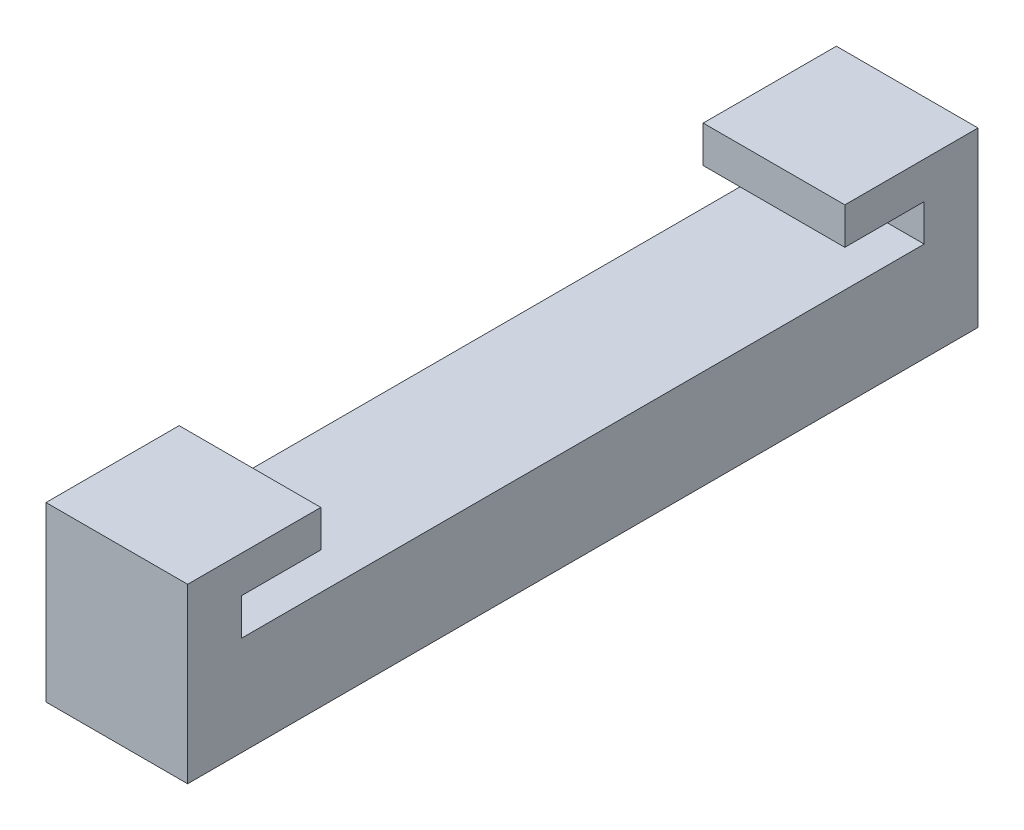
from build123d import *

# Parameters (mm, degrees)
BOSS_EXTRUDE1_DEPTH = 12.7
BOSS_EXTRUDE3_DEPTH = 12.7
CUT_EXTRUDE1_REACH  = 14.7
CUT_EXTRUDE2_REACH  = 14.7
SKETCH6_W           = 7.112
SKETCH6_H           = 3.302
BOSS_EXTRUDE4_DEPTH = 3.175
SKETCH7_W           = 7.112
SKETCH7_H           = 3.302
BOSS_EXTRUDE5_DEPTH = 3.175
CUT_EXTRUDE3_REACH  = 14.7
SKETCH8_W           = 7.112
SKETCH8_H           = 3.302
CUT_EXTRUDE4_REACH  = 14.7
SKETCH9_W           = 7.112
SKETCH9_H           = 3.302


with BuildPart() as part:
    # Sketch1 → Boss-Extrude1 (new body)
    with BuildSketch(Plane(origin=(0, 0, 0), x_dir=(0, 0, -1), z_dir=(1, 0, 0))):
        Polygon((0, 0), (80.01, 0), (80.01, 19.05), (71.12, 19.05), (71.12, 8.89), (8.89, 8.89), (8.89, 19.05), (0, 19.05), align=None)
    extrude(amount=BOSS_EXTRUDE1_DEPTH)

    # Sketch2 → Boss-Extrude3 (add)
    with BuildSketch(Plane.ZY):
        Polygon((-63.5, 12.192), (-70.612, 12.192), (-70.612, 8.89), (-74.93, 8.89), (-74.93, 15.494), (-63.5, 15.494), align=None)
        Polygon((-16.51, 12.192), (-9.398, 12.192), (-9.398, 8.89), (-5.08, 8.89), (-5.08, 15.494), (-16.51, 15.494), align=None)
    extrude(amount=-BOSS_EXTRUDE3_DEPTH)

    # Sketch4 → Cut-Extrude1 (cut, up to next)
    with BuildSketch(Plane.ZY, mode=Mode.PRIVATE) as cut_extrude1_sk1:
        Polygon((-71.12, 15.494), (-75.438, 15.494), (-75.438, 0), (-80.01, 0), (-80.01, 19.05), (-71.12, 19.05), align=None)
    cut_extrude1_tool1 = extrude(cut_extrude1_sk1.sketch, amount=-CUT_EXTRUDE1_REACH, mode=Mode.PRIVATE) & part.part
    add(cut_extrude1_tool1.solids().sort_by_distance((0, 10.686074, -77.05781))[0], mode=Mode.SUBTRACT)

    # Sketch5 → Cut-Extrude2 (cut, up to next)
    with BuildSketch(Plane.ZY, mode=Mode.PRIVATE) as cut_extrude2_sk1:
        Polygon((-8.89, 15.494), (-4.572, 15.494), (-4.572, 0), (0, 0), (0, 19.05), (-8.89, 19.05), align=None)
    cut_extrude2_tool1 = extrude(cut_extrude2_sk1.sketch, amount=-CUT_EXTRUDE2_REACH, mode=Mode.PRIVATE) & part.part
    add(cut_extrude2_tool1.solids().sort_by_distance((0, 10.686074, -2.95219))[0], mode=Mode.SUBTRACT)

    # Sketch6 → Boss-Extrude4 (add)
    with BuildSketch(Plane(origin=(12.7, 0, 0), x_dir=(0, 0, -1), z_dir=(1, 0, 0))):
        with Locations((12.954, 10.541)):
            Rectangle(SKETCH6_W, SKETCH6_H)
    extrude(amount=-BOSS_EXTRUDE4_DEPTH)

    # Sketch7 → Boss-Extrude5 (add)
    with BuildSketch(Plane(origin=(12.7, 0, 0), x_dir=(0, 0, -1), z_dir=(1, 0, 0))):
        with Locations((67.056, 10.541)):
            Rectangle(SKETCH7_W, SKETCH7_H)
    extrude(amount=-BOSS_EXTRUDE5_DEPTH)

    # Sketch8 → Cut-Extrude3 (cut, up to next)
    with BuildSketch(Plane(origin=(12.7, 0, 0), x_dir=(0, 0, -1), z_dir=(1, 0, 0)), mode=Mode.PRIVATE) as cut_extrude3_sk1:
        with Locations((12.954, 10.541)):
            Rectangle(SKETCH8_W, SKETCH8_H)
    cut_extrude3_tool1 = extrude(cut_extrude3_sk1.sketch, amount=-CUT_EXTRUDE3_REACH, mode=Mode.PRIVATE) & part.part
    add(cut_extrude3_tool1.solids().sort_by_distance((12.7, 10.541, -12.954))[0], mode=Mode.SUBTRACT)

    # Sketch9 → Cut-Extrude4 (cut, up to next)
    with BuildSketch(Plane(origin=(12.7, 0, 0), x_dir=(0, 0, -1), z_dir=(1, 0, 0)), mode=Mode.PRIVATE) as cut_extrude4_sk1:
        with Locations((67.056, 10.541)):
            Rectangle(SKETCH9_W, SKETCH9_H)
    cut_extrude4_tool1 = extrude(cut_extrude4_sk1.sketch, amount=-CUT_EXTRUDE4_REACH, mode=Mode.PRIVATE) & part.part
    add(cut_extrude4_tool1.solids().sort_by_distance((12.7, 10.541, -67.056))[0], mode=Mode.SUBTRACT)


solid = part.part
